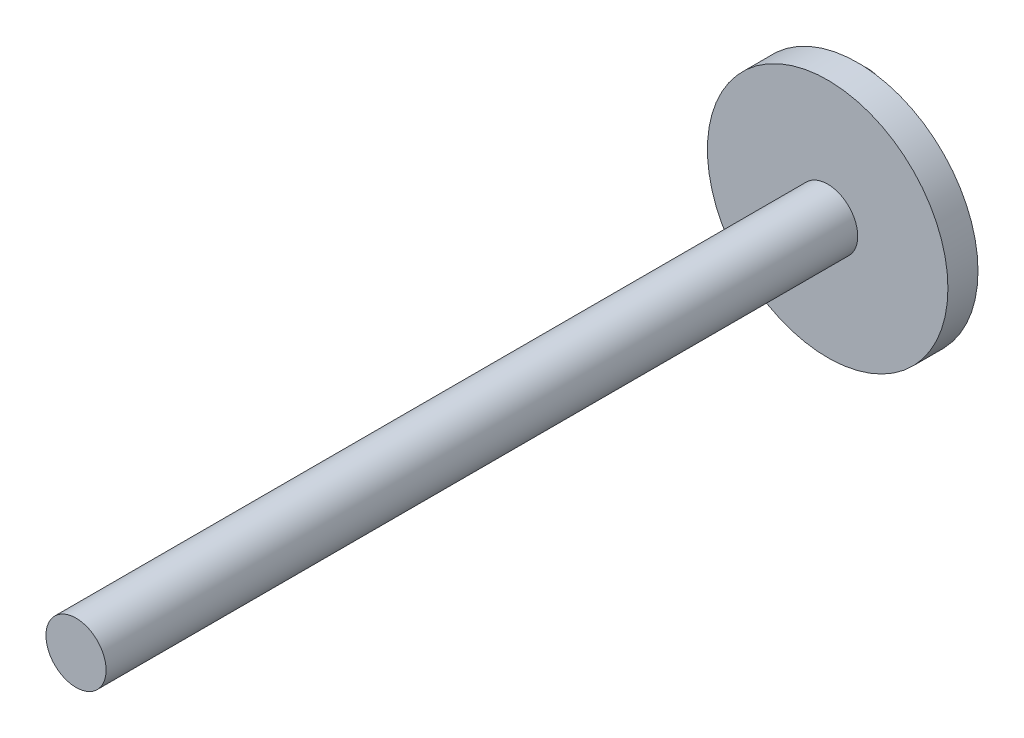
from build123d import *

# Parameters (mm, degrees)
SKETCH1_R           = 40
BOSS_EXTRUDE1_DEPTH = 10
SKETCH2_R           = 10
BOSS_EXTRUDE2_DEPTH = 250
SKETCH3_R           = 10
BOSS_EXTRUDE3_DEPTH = 30


with BuildPart() as part:
    # Sketch1 → Boss-Extrude1 (new body)
    with BuildSketch(Plane.XY):
        Circle(SKETCH1_R)
    extrude(amount=BOSS_EXTRUDE1_DEPTH)

    # Sketch2 → Boss-Extrude2 (add)
    with BuildSketch(Plane.XY.offset(10)):
        Circle(SKETCH2_R)
    extrude(amount=BOSS_EXTRUDE2_DEPTH)

    # Sketch3 → Boss-Extrude3 (add)
    with BuildSketch(Plane(origin=(0, 0, 0), x_dir=(-1, 0, 0), z_dir=(0, 0, -1))):
        with Locations((26.998561916, 0)):
            Circle(SKETCH3_R)
    extrude(amount=BOSS_EXTRUDE3_DEPTH)


solid = part.part
